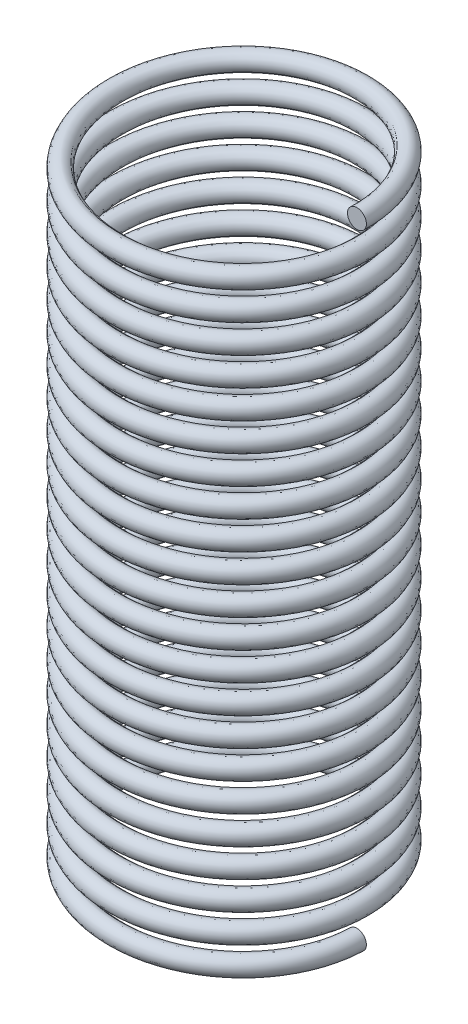
from build123d import *

# Parameters (mm, degrees)
SWEEP_1_PITCH       = 3
SWEEP_1_HEIGHT      = 66
SWEEP_1_RADIUS      = 13
SWEEP_1_START_ANGLE = 90
SKETCH_4_R          = 1


with BuildPart() as part:
    # 扫描1: sweep along a helix
    with BuildLine() as sweep_1_path:
        add(Helix(SWEEP_1_PITCH, SWEEP_1_HEIGHT, SWEEP_1_RADIUS, center=(0, 0, 0), direction=(0, 1, 0), lefthand=True, mode=Mode.PRIVATE).rotate(Axis((0, 0, 0), (0, 1, 0)), SWEEP_1_START_ANGLE))
    # 草图4 → 扫描1 (sweep)
    with BuildSketch(Plane.XY):
        with Locations((13, 66)):
            Circle(SKETCH_4_R)
    sweep(path=sweep_1_path.line, is_frenet=True)


solid = part.part
